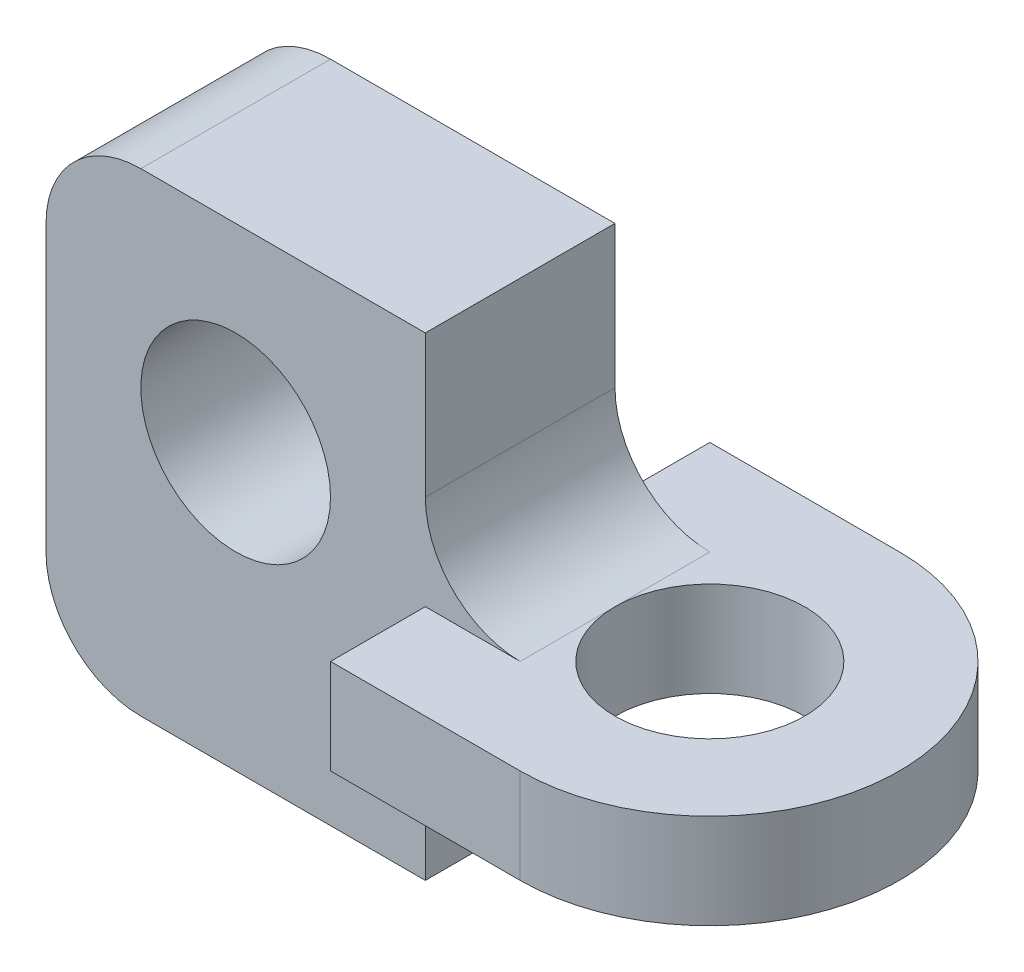
from build123d import *

# Parameters (mm, degrees)
SKETCH_1_R      = 5
EXTRUDE_1_DEPTH = 2.5
SKETCH_2_R      = 5
EXTRUDE_2_DEPTH = 5
FILLET_1_R      = 5


with BuildPart() as part:
    # 草圖1 → 填料-伸長1 (new, symmetric)
    with BuildSketch(Plane(origin=(0, 0, 0), x_dir=(1, 0, 0), z_dir=(0, 1, 0))):
        with BuildLine():
            Line((0, 10), (-10, 10))
            Line((-10, 10), (-10, -10))
            Line((-10, -10), (0, -10))
            ThreePointArc((0, -10), (10, 0), (0, 10))
        make_face()
        with Locations(Location((0, 0, 0), (0, 0, 270))):
            Circle(SKETCH_1_R, mode=Mode.SUBTRACT)
    extrude(amount=EXTRUDE_1_DEPTH, both=True)

    # 草圖2 → 填料-伸長2 (add, symmetric)
    with BuildSketch(Plane.XY):
        with BuildLine():
            Line((-30, 1.898257061), (-30, -5))
            ThreePointArc((-30, -5), (-28.535533906, -8.535533906), (-25, -10))
            Line((-25, -10), (-10, -10))
            Line((-10, -10), (-10, -2.5))
            Line((-10, -2.5), (-10, 2.5))
            Line((-10, 2.5), (-10, 15))
            Line((-10, 15), (-25, 15))
            ThreePointArc((-25, 15), (-28.535533906, 13.535533906), (-30, 10))
            Line((-30, 10), (-30, 1.898257061))
        make_face()
        with Locations((-20, 5)):
            Circle(SKETCH_2_R, mode=Mode.SUBTRACT)
    extrude(amount=EXTRUDE_2_DEPTH, both=True)

    # 圓角1
    fillet_1_edges = [part.edges().sort_by_distance(p)[0] for p in [
        (-10, -2.5, 0),
        (-10, 2.5, 0),
    ]]
    fillet(fillet_1_edges, radius=FILLET_1_R)


solid = part.part
